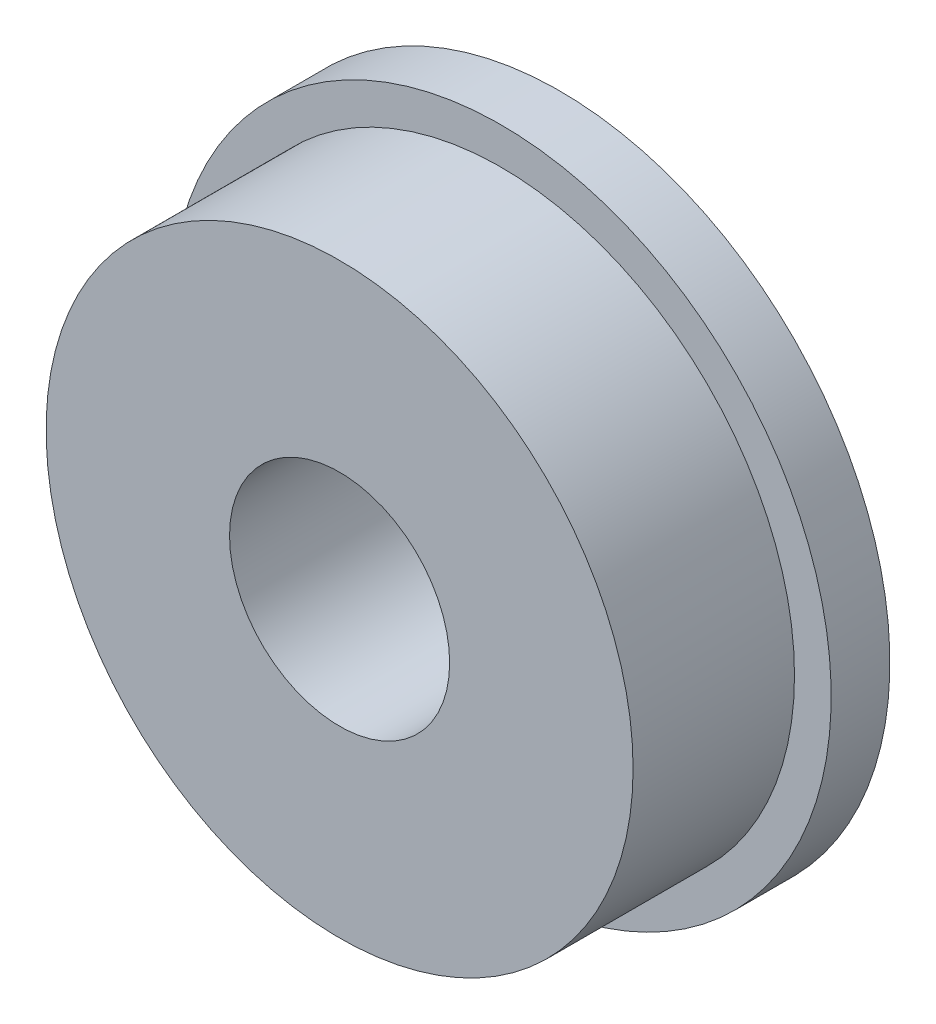
from build123d import *

# Parameters (mm, degrees)
SKETCH_1_R          = 4
EXTRUDE_1_DEPTH     = 2.2
SKETCH_2_R          = 1.5
CUT_EXTRUDE_1_DEPTH = 7
SKETCH_3_R          = 4.5
EXTRUDE_2_DEPTH     = 0.8
SKETCH_4_R          = 1.5
CUT_EXTRUDE_2_DEPTH = 0.8


with BuildPart() as part:
    # 草图1 → 凸台-拉伸1 (new body)
    with BuildSketch(Plane.XY):
        Circle(SKETCH_1_R)
    extrude(amount=EXTRUDE_1_DEPTH)

    # 草图2 → 切除-拉伸1 (cut)
    with BuildSketch(Plane.XY.offset(2.2)):
        Circle(SKETCH_2_R)
    extrude(amount=-CUT_EXTRUDE_1_DEPTH, mode=Mode.SUBTRACT)

    # 草图3 → 凸台-拉伸2 (add)
    with BuildSketch(Plane(origin=(0, 0, 0), x_dir=(-1, 0, 0), z_dir=(0, 0, -1))):
        Circle(SKETCH_3_R)
    extrude(amount=EXTRUDE_2_DEPTH)

    # 草图4 → 切除-拉伸2 (cut)
    with BuildSketch(Plane.XY):
        Circle(SKETCH_4_R)
    extrude(amount=-CUT_EXTRUDE_2_DEPTH, mode=Mode.SUBTRACT)


solid = part.part
